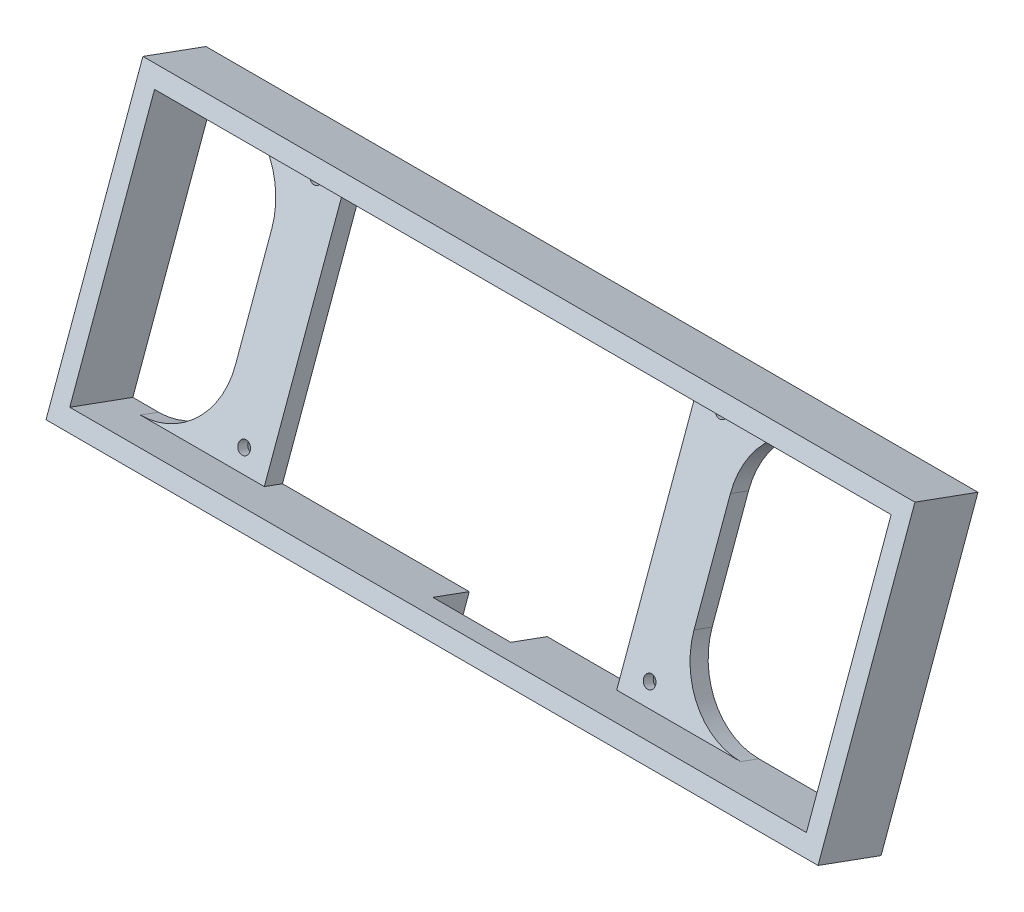
from build123d import *

# Parameters (mm, degrees)
ESQUISSE1_W             = 218
ESQUISSE1_H             = 80
ESQUISSE1_W_2           = 208
ESQUISSE1_H_2           = 70
BOSS_EXTRU_1_DEPTH      = 16.5
ESQUISSE2_W             = 15
ESQUISSE2_H             = 80
ESQUISSE2_R             = 3.25
BOSS_EXTRU_2_DEPTH      = 2.45
ESQUISSE3_W             = 22
ESQUISSE3_H             = 5
ENL_V_MAT_EXTRU_1_DEPTH = 16.5
ESQUISSE4_W             = 15
ESQUISSE4_H             = 70
ESQUISSE4_R             = 1.7
BOSS_EXTRU_3_DEPTH      = 3
CONG_1_R                = 20
ESQUISSE7_W             = 22
ESQUISSE7_H             = 5
BOSS_EXTRU_5_DEPTH      = 8
ESQUISSE8_W             = 52.75
ESQUISSE8_H             = 5
ESQUISSE8_W_2           = 24.75
ESQUISSE8_W_3           = 99.5
BOSS_EXTRU_6_DEPTH      = 2.45


with BuildPart() as part:
    # Esquisse1 → Boss.-Extru.1 (new body)
    with BuildSketch(Plane(origin=(0, 0, 0), x_dir=(1, 0, 0), z_dir=(0, 0.342020143, 0.939692621))):
        Rectangle(ESQUISSE1_W, ESQUISSE1_H)
        Rectangle(ESQUISSE1_W_2, ESQUISSE1_H_2, mode=Mode.SUBTRACT)
    extrude(amount=BOSS_EXTRU_1_DEPTH)

    # Esquisse2 → Boss.-Extru.2 (add)
    with BuildSketch(Plane(origin=(0, 0, 0), x_dir=(-1, 0, 0), z_dir=(0, -0.342020143, -0.939692621))):
        with Locations((-45.25, 0)):
            Rectangle(ESQUISSE2_W, ESQUISSE2_H)
        with Locations((-45.25, 29.75)):
            Circle(ESQUISSE2_R, mode=Mode.SUBTRACT)
        with Locations((-45.25, -29.75)):
            Circle(ESQUISSE2_R, mode=Mode.SUBTRACT)
        with Locations((69.25, 0)):
            Rectangle(ESQUISSE2_W, ESQUISSE2_H)
        with Locations((69.25, 29.75)):
            Circle(ESQUISSE2_R, mode=Mode.SUBTRACT)
        with Locations((69.25, -29.75)):
            Circle(ESQUISSE2_R, mode=Mode.SUBTRACT)
    extrude(amount=BOSS_EXTRU_2_DEPTH)

    # Esquisse3 → Enlèv. mat.-Extru.1 (cut)
    with BuildSketch(Plane(origin=(0, 5.643332365, 15.504928243), x_dir=(1, 0, 0), z_dir=(0, 0.342020143, 0.939692621))):
        with Locations((2, -37.5)):
            Rectangle(ESQUISSE3_W, ESQUISSE3_H)
    extrude(amount=-ENL_V_MAT_EXTRU_1_DEPTH, mode=Mode.SUBTRACT)

    # Esquisse4 → Boss.-Extru.3 (add)
    with BuildSketch(Plane(origin=(0, 0, 0), x_dir=(1, 0, 0), z_dir=(0, 0.342020143, 0.939692621))):
        with Locations((45.25, 0)):
            Rectangle(ESQUISSE4_W, ESQUISSE4_H)
        with Locations((45.25, -29.75)):
            Circle(ESQUISSE4_R, mode=Mode.SUBTRACT)
        with Locations((45.25, 29.75)):
            Circle(ESQUISSE4_R, mode=Mode.SUBTRACT)
        with Locations((-69.25, 0)):
            Rectangle(ESQUISSE4_W, ESQUISSE4_H)
        with Locations((-69.25, 29.75)):
            Circle(ESQUISSE4_R, mode=Mode.SUBTRACT)
        with Locations((-69.25, -29.75)):
            Circle(ESQUISSE4_R, mode=Mode.SUBTRACT)
    extrude(amount=BOSS_EXTRU_3_DEPTH)

    # Congé1
    cong_1_edges = [part.edges().sort_by_distance(p)[0] for p in [
        (52.75, -32.376211513, 13.380243948),
        (52.75, 33.402271942, -10.561166085),
        (-76.75, 33.402271942, -10.561166085),
        (-76.75, -32.376211513, 13.380243948),
    ]]
    fillet(cong_1_edges, radius=CONG_1_R)

    # Esquisse7 → Boss.-Extru.5 (add)
    with BuildSketch(Plane(origin=(0, 5.643332365, 15.504928243), x_dir=(1, 0, 0), z_dir=(0, 0.342020143, 0.939692621))):
        with Locations((2, -37.5)):
            Rectangle(ESQUISSE7_W, ESQUISSE7_H)
    extrude(amount=-BOSS_EXTRU_5_DEPTH)

    # Esquisse8 → Boss.-Extru.6 (add)
    with BuildSketch(Plane(origin=(0, 0, 0), x_dir=(-1, 0, 0), z_dir=(0, -0.342020143, -0.939692621))):
        with BuildLine():
            Line((76.75, -15), (76.75, -40))
            Line((76.75, -40), (109, -40))
            Line((109, -40), (109, 40))
            Line((109, 40), (76.75, 40))
            Line((76.75, 40), (76.75, 15))
            ThreePointArc((76.75, 15), (82.607864376, 29.142135624), (96.75, 35))
            Line((96.75, 35), (104, 35))
            Line((104, 35), (104, -35))
            Line((104, -35), (96.75, -35))
            ThreePointArc((96.75, -35), (82.607864376, -29.142135624), (76.75, -15))
        make_face()
        with BuildLine():
            Line((-52.75, 15), (-52.75, 40))
            Line((-52.75, 40), (-109, 40))
            Line((-109, 40), (-109, -40))
            Line((-109, -40), (-52.75, -40))
            Line((-52.75, -40), (-52.75, -15))
            ThreePointArc((-52.75, -15), (-58.607864376, -29.142135624), (-72.75, -35))
            Line((-72.75, -35), (-104, -35))
            Line((-104, -35), (-104, 35))
            Line((-104, 35), (-72.75, 35))
            ThreePointArc((-72.75, 35), (-58.607864376, 29.142135624), (-52.75, 15))
        make_face()
        with Locations((35.375, -37.5)):
            Rectangle(ESQUISSE8_W, ESQUISSE8_H)
        with Locations((-25.375, -37.5)):
            Rectangle(ESQUISSE8_W_2, ESQUISSE8_H)
        with Locations((12, 37.5)):
            Rectangle(ESQUISSE8_W_3, ESQUISSE8_H)
    extrude(amount=BOSS_EXTRU_6_DEPTH)


solid = part.part
